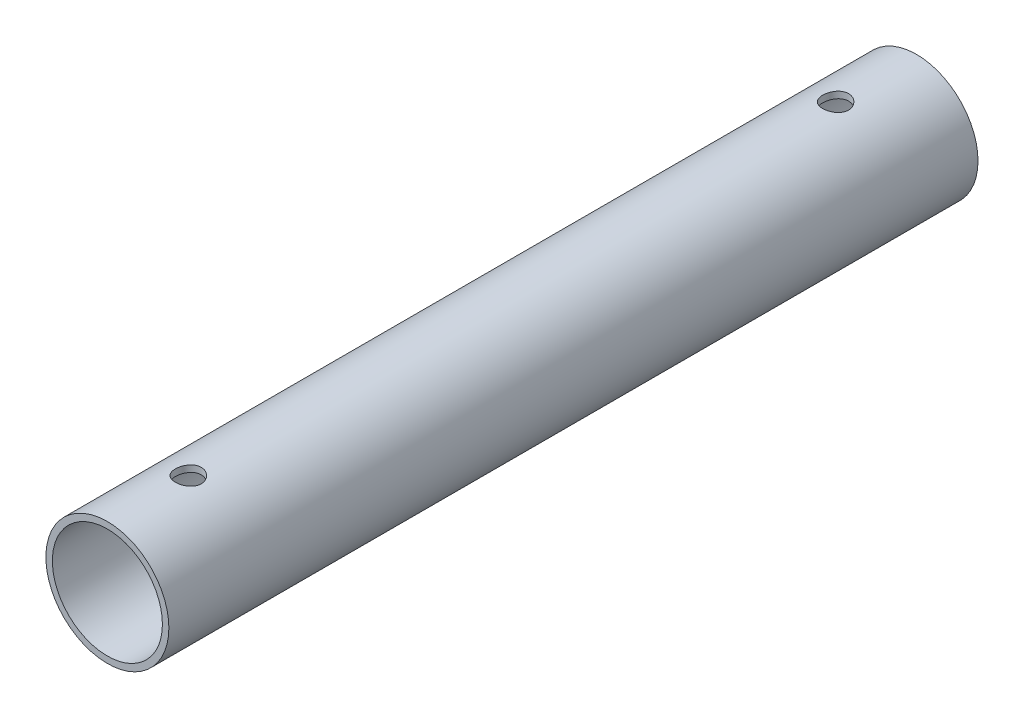
from build123d import *

# Parameters (mm, degrees)
SKETCH1_R           = 19
SKETCH1_R_2         = 17
BOSS_EXTRUDE1_DEPTH = 125
SKETCH4_R           = 4
CUT_EXTRUDE3_DEPTH  = 41


with BuildPart() as part:
    # Sketch1 → Boss-Extrude1 (new body, symmetric)
    with BuildSketch(Plane.XY):
        Circle(SKETCH1_R)
        Circle(SKETCH1_R_2, mode=Mode.SUBTRACT)
    extrude(amount=BOSS_EXTRUDE1_DEPTH, both=True)

    # Sketch4 → Cut-Extrude3 (cut, through all)
    with BuildSketch(Plane(origin=(0, 21, 0), x_dir=(1, 0, 0), z_dir=(0, 1, 0))):
        with Locations((0, -100)):
            Circle(SKETCH4_R)
    cut_extrude3 = extrude(amount=-CUT_EXTRUDE3_DEPTH, mode=Mode.SUBTRACT)

    # Mirror1: Cut-Extrude3 across plane
    add(cut_extrude3.mirror(Plane.XY), mode=Mode.SUBTRACT)


solid = part.part
